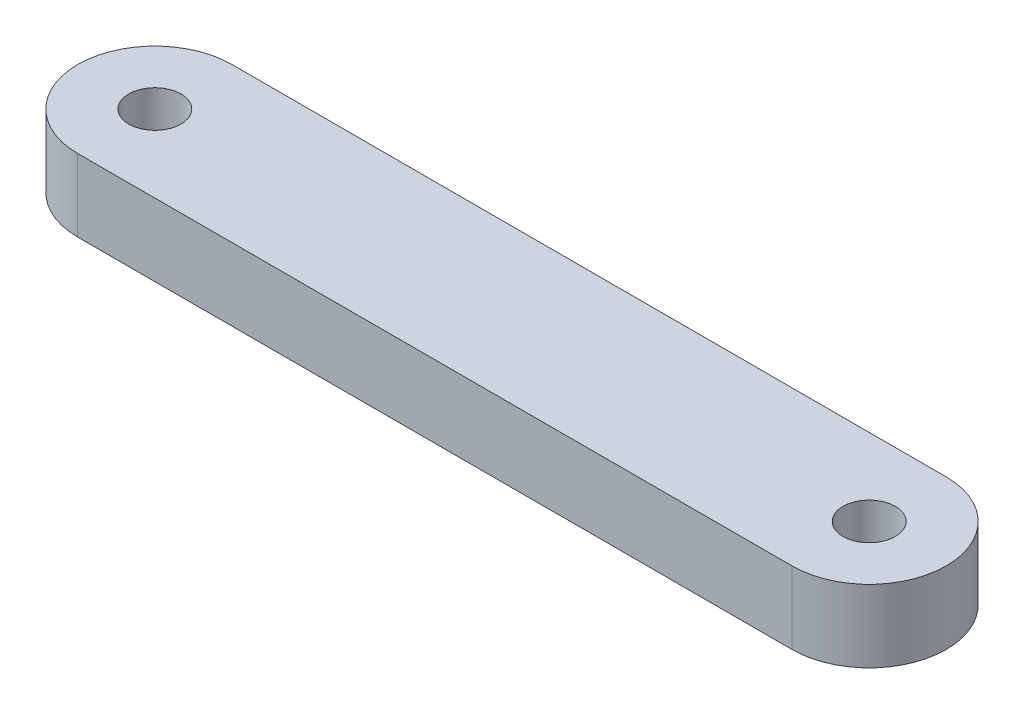
from build123d import *

# Parameters (mm, degrees)
SKETCH1_R           = 2.29235
BOSS_EXTRUDE1_DEPTH = 6.35


with BuildPart() as part:
    # Sketch1 → Boss-Extrude1 (new body)
    with BuildSketch(Plane(origin=(0, 0, 0), x_dir=(1, 0, 0), z_dir=(0, 1, 0))):
        with BuildLine():
            Line((0, -6.765240676), (-62.669518648, -6.765240676))
            ThreePointArc((-62.669518648, -6.765240676), (-69.434759324, 0), (-62.669518648, 6.765240676))
            Line((-62.669518648, 6.765240676), (0, 6.765240676))
            ThreePointArc((0, 6.765240676), (6.765240676, 0), (0, -6.765240676))
        make_face()
        with Locations((-62.669518648, 0)):
            Circle(SKETCH1_R, mode=Mode.SUBTRACT)
        Circle(SKETCH1_R, mode=Mode.SUBTRACT)
    extrude(amount=BOSS_EXTRUDE1_DEPTH)


solid = part.part
